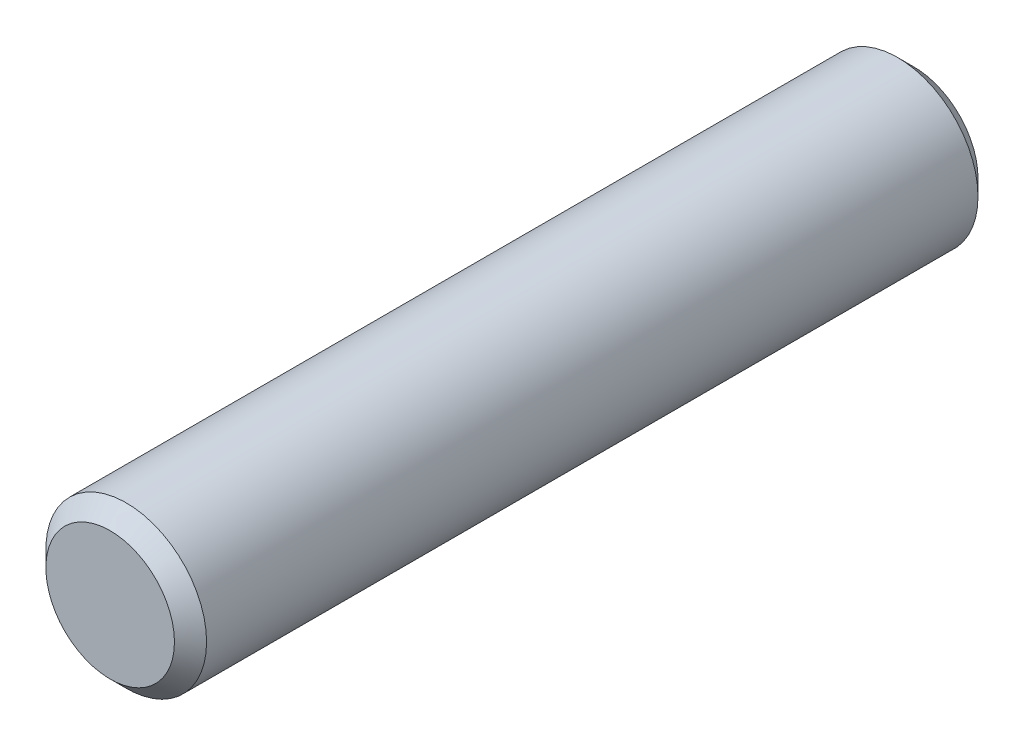
from build123d import *

# Parameters (mm, degrees)
SKETCH_1_R      = 1
EXTRUDE_1_DEPTH = 5
CHAMFER_1_SIZE  = 0.2


with BuildPart() as part:
    # 草图1 → 凸台-拉伸1 (new body, symmetric)
    with BuildSketch(Plane.XY):
        Circle(SKETCH_1_R)
    extrude(amount=EXTRUDE_1_DEPTH, both=True)

    # 倒角1
    chamfer_1_edges = [part.edges().sort_by_distance(p)[0] for p in [
        (-1, 0, -5),
        (-1, 0, 5),
    ]]
    chamfer(chamfer_1_edges, length=CHAMFER_1_SIZE)


solid = part.part
